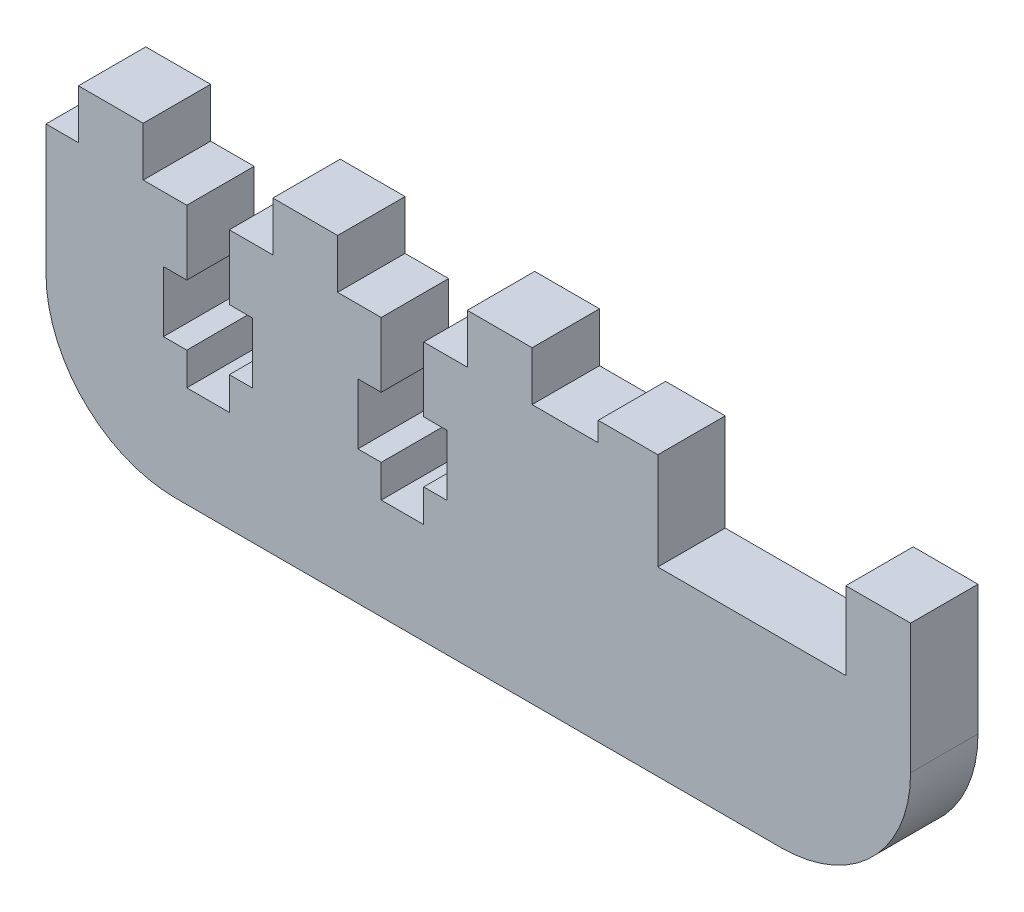
from build123d import *

# Parameters (mm, degrees)
BOSS_EXTRUDE1_DEPTH = 6.604
CUT_EXTRUDE1_DEPTH  = 7.604
SKETCH3_W           = 6.35
SKETCH3_H           = 4.826
BOSS_EXTRUDE2_DEPTH = 6.604
FILLET1_R           = 12.7


with BuildPart() as part:
    # Sketch1 → Boss-Extrude1 (new body)
    with BuildSketch(Plane.XY):
        Polygon((-6.858, 0), (-6.858, -9.525), (11.557, -9.525), (11.557, -1.905), (17.907, -1.905), (17.907, -27.305), (-66.802, -27.305), (-66.802, -1.905), (-12.7, -1.905), (-12.7, 0), align=None)
    extrude(amount=BOSS_EXTRUDE1_DEPTH)

    # Sketch2 → Cut-Extrude1 (cut, through all)
    with BuildSketch(Plane.XY.offset(6.604)):
        Polygon((-53.0098, -1.905), (-53.0098, -8.255), (-55.2958, -8.255), (-55.2958, -14.1986), (-53.0098, -14.1986), (-53.0098, -17.399), (-48.8442, -17.399), (-48.8442, -14.1986), (-46.5582, -14.1986), (-46.5582, -8.255), (-48.8442, -8.255), (-48.8442, -1.905), align=None)
        Polygon((-33.9598, -1.905), (-33.9598, -8.255), (-36.2458, -8.255), (-36.2458, -14.1986), (-33.9598, -14.1986), (-33.9598, -17.399), (-29.7942, -17.399), (-29.7942, -14.1986), (-27.5082, -14.1986), (-27.5082, -8.255), (-29.7942, -8.255), (-29.7942, -1.905), align=None)
    extrude(amount=-CUT_EXTRUDE1_DEPTH, mode=Mode.SUBTRACT)

    # Sketch3 → Boss-Extrude2 (add)
    with BuildSketch(Plane.XY.offset(6.604)):
        with Locations((-60.452, 0.508)):
            Rectangle(SKETCH3_W, SKETCH3_H)
        with Locations((-41.402, 0.508)):
            Rectangle(SKETCH3_W, SKETCH3_H)
        with Locations((-22.352, 0.508)):
            Rectangle(SKETCH3_W, SKETCH3_H)
    extrude(amount=-BOSS_EXTRUDE2_DEPTH)

    # Fillet1
    fillet1_edges = [part.edges().sort_by_distance(p)[0] for p in [
        (17.907, -27.305, 3.302),
        (-66.802, -27.305, 3.302),
    ]]
    fillet(fillet1_edges, radius=FILLET1_R)


solid = part.part
